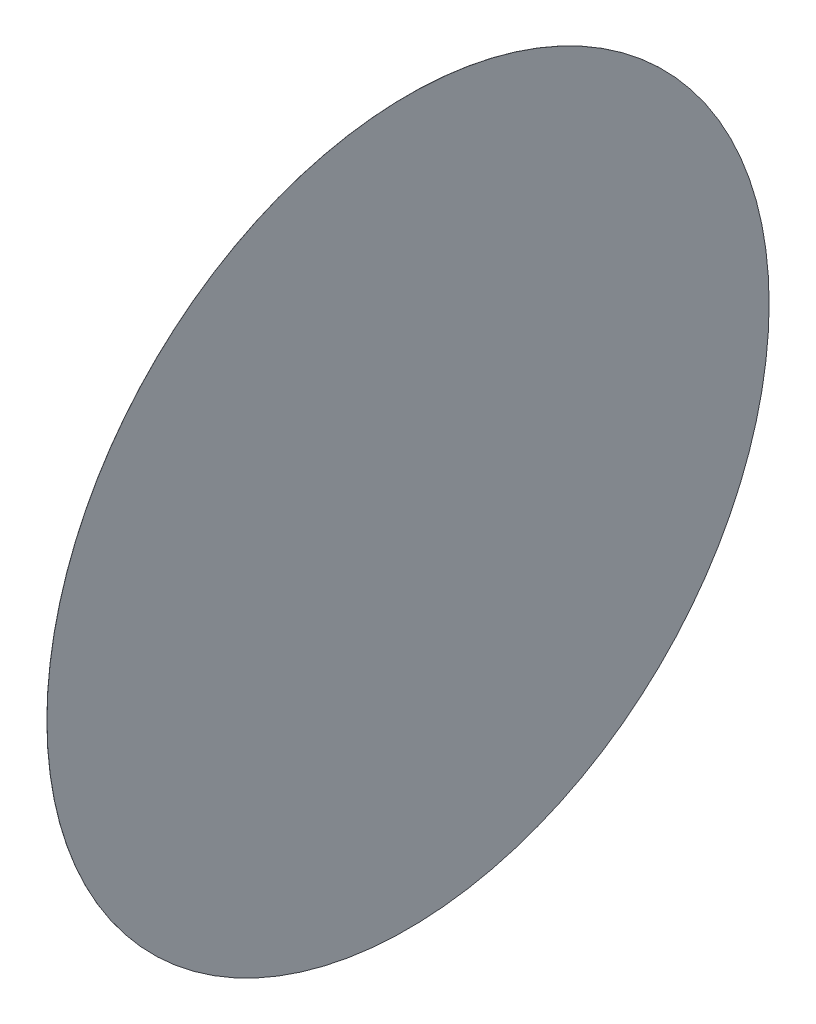
from build123d import *

# Parameters (mm, degrees)
SKETCH1_R           = 4
BOSS_EXTRUDE1_DEPTH = 0.001


with BuildPart() as part:
    # Sketch1 → Boss-Extrude1 (new body)
    with BuildSketch(Plane(origin=(0, 0, 0), x_dir=(0, 0, -1), z_dir=(1, 0, 0))):
        Circle(SKETCH1_R)
    extrude(amount=BOSS_EXTRUDE1_DEPTH)


solid = part.part
